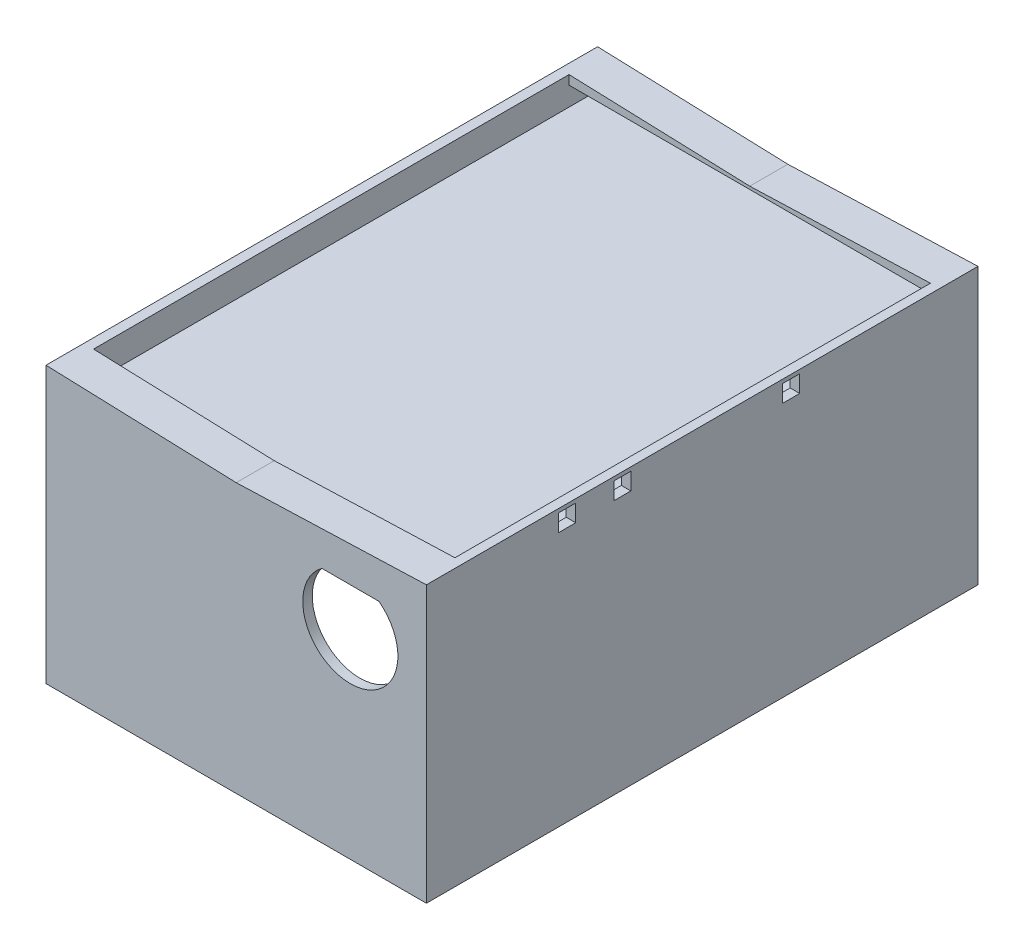
from build123d import *

# Parameters (mm, degrees)
SKETCH1_W            = 200
SKETCH1_H            = 290
BOSS_EXTRUDE2_DEPTH  = 10
BOSS_EXTRUDE4_DEPTH  = 140
SKETCH5_W            = 9
SKETCH5_H            = 9
CUT_EXTRUDE1_DEPTH   = 10
SKETCH6_R            = 3.78
CUT_EXTRUDE2_DEPTH   = 10
SKETCH7_R            = 25
CUT_EXTRUDE3_DEPTH   = 10
SKETCH8_W            = 190
SKETCH8_H            = 280
CUT_EXTRUDE4_DEPTH   = 10
SKETCH9_W            = 211.457715155
SKETCH9_H            = 301.376650104
CUT_EXTRUDE5_DEPTH   = 5
SKETCH10_W           = 200
SKETCH10_H           = 5
BOSS_EXTRUDE7_DEPTH  = 15
SKETCH12_W           = 200
SKETCH12_H           = 5
BOSS_EXTRUDE8_DEPTH  = 15
SKETCH13_W           = 290
SKETCH13_H           = 5
BOSS_EXTRUDE14_DEPTH = 190
CUT_EXTRUDE6_DEPTH   = 300
SKETCH18_W           = 9
SKETCH18_H           = 9
CUT_EXTRUDE7_DEPTH   = 10


with BuildPart() as part:
    # Sketch1 → Boss-Extrude2 (new body)
    with BuildSketch(Plane(origin=(0, 0, 0), x_dir=(1, 0, 0), z_dir=(0, 1, 0))):
        with Locations((3.938356164, -87.893835616)):
            Rectangle(SKETCH1_W, SKETCH1_H)
    extrude(amount=BOSS_EXTRUDE2_DEPTH)

    # Sketch2 → Boss-Extrude4 (add)
    with BuildSketch(Plane(origin=(0, 10, 0), x_dir=(1, 0, 0), z_dir=(0, 1, 0))):
        Polygon((-96.061643836, 57.106164384), (-96.061643836, -87.893835616), (-91.061643836, -87.893835616), (-91.061643836, 52.106164384), (3.938356164, 52.106164384), (3.938356164, 57.106164384), align=None)
        Polygon((103.938356164, 57.106164384), (3.938356164, 57.106164384), (3.938356164, 52.106164384), (98.938356164, 52.106164384), (98.938356164, -87.893835616), (103.938356164, -87.893835616), align=None)
        Polygon((3.938356164, -227.893835616), (3.938356164, -232.893835616), (103.938356164, -232.893835616), (103.938356164, -87.893835616), (98.938356164, -87.893835616), (98.938356164, -227.893835616), align=None)
        Polygon((-91.061643836, -87.893835616), (-96.061643836, -87.893835616), (-96.061643836, -232.893835616), (3.938356164, -232.893835616), (3.938356164, -227.893835616), (-91.061643836, -227.893835616), align=None)
    extrude(amount=BOSS_EXTRUDE4_DEPTH)

    # Sketch5 → Cut-Extrude1 (cut)
    with BuildSketch(Plane(origin=(103.938356164, 0, 0), x_dir=(0, 0, -1), z_dir=(1, 0, 0))):
        with Locations((-158.893835616, 143.5)):
            Rectangle(SKETCH5_W, SKETCH5_H)
        with Locations((-129.893835616, 143.5)):
            Rectangle(SKETCH5_W, SKETCH5_H)
        with Locations((-41.143835616, 143.5)):
            Rectangle(SKETCH5_W, SKETCH5_H)
    extrude(amount=-CUT_EXTRUDE1_DEPTH, mode=Mode.SUBTRACT)

    # Sketch6 → Cut-Extrude2 (cut)
    with BuildSketch(Plane.ZY.offset(96.061643836)):
        with Locations((189.256335616, 112.5)):
            Circle(SKETCH6_R)
        with Locations((-13.468664384, 112.5)):
            Circle(SKETCH6_R)
        with Locations((189.256335616, 61.57)):
            Circle(SKETCH6_R)
        with Locations((-13.468664384, 61.57)):
            Circle(SKETCH6_R)
    extrude(amount=-CUT_EXTRUDE2_DEPTH, mode=Mode.SUBTRACT)

    # Sketch7 → Cut-Extrude3 (cut)
    with BuildSketch(Plane.XY.offset(232.893835616)):
        with Locations((63.938356164, 110)):
            Circle(SKETCH7_R)
    extrude(amount=-CUT_EXTRUDE3_DEPTH, mode=Mode.SUBTRACT)

    # Sketch8 → Cut-Extrude4 (cut)
    with BuildSketch(Plane(origin=(0, 10, 0), x_dir=(1, 0, 0), z_dir=(0, 1, 0))):
        with Locations((3.938356164, -87.893835616)):
            Rectangle(SKETCH8_W, SKETCH8_H)
    extrude(amount=-CUT_EXTRUDE4_DEPTH, mode=Mode.SUBTRACT)

    # Sketch9 → Cut-Extrude5 (cut)
    with BuildSketch(Plane.XZ):
        with Locations((3.40694666, 89.005470801)):
            Rectangle(SKETCH9_W, SKETCH9_H)
    extrude(amount=-CUT_EXTRUDE5_DEPTH, mode=Mode.SUBTRACT)

    # Sketch10 → Boss-Extrude7 (add)
    with BuildSketch(Plane(origin=(0, 0, 227.893835616), x_dir=(-1, 0, 0), z_dir=(0, 0, -1))):
        with Locations((-3.938356164, 147.5)):
            Rectangle(SKETCH10_W, SKETCH10_H)
    extrude(amount=BOSS_EXTRUDE7_DEPTH)

    # Sketch12 → Boss-Extrude8 (add)
    with BuildSketch(Plane.XY.offset(-52.106164384)):
        with Locations((3.938356164, 147.5)):
            Rectangle(SKETCH12_W, SKETCH12_H)
    extrude(amount=BOSS_EXTRUDE8_DEPTH)

    # Sketch13 → Boss-Extrude14 (add)
    with BuildSketch(Plane(origin=(-91.061643836, 0, 0), x_dir=(0, 0, -1), z_dir=(1, 0, 0))):
        with Locations((-87.893835616, 132.5)):
            Rectangle(SKETCH13_W, SKETCH13_H)
    extrude(amount=BOSS_EXTRUDE14_DEPTH)

    # Sketch17 → Cut-Extrude6 (cut)
    with BuildSketch(Plane.XY.offset(232.893835616)):
        Polygon((3.938356164, 150), (-96.061643836, 150), (3.938356164, 146.51), align=None)
        Polygon((103.938356164, 150), (3.938356164, 150), (3.938356164, 146.51), align=None)
    extrude(amount=-CUT_EXTRUDE6_DEPTH, mode=Mode.SUBTRACT)

    # Sketch18 → Cut-Extrude7 (cut)
    with BuildSketch(Plane(origin=(0, 135, 0), x_dir=(1, 0, 0), z_dir=(0, 1, 0))):
        with Locations((89.633915759, -41.143835616)):
            Rectangle(SKETCH18_W, SKETCH18_H)
        with Locations((91.172972479, -129.893835616)):
            Rectangle(SKETCH18_W, SKETCH18_H)
        with Locations((91.172972479, -158.893835616)):
            Rectangle(SKETCH18_W, SKETCH18_H)
    extrude(amount=-CUT_EXTRUDE7_DEPTH, mode=Mode.SUBTRACT)


solid = part.part
